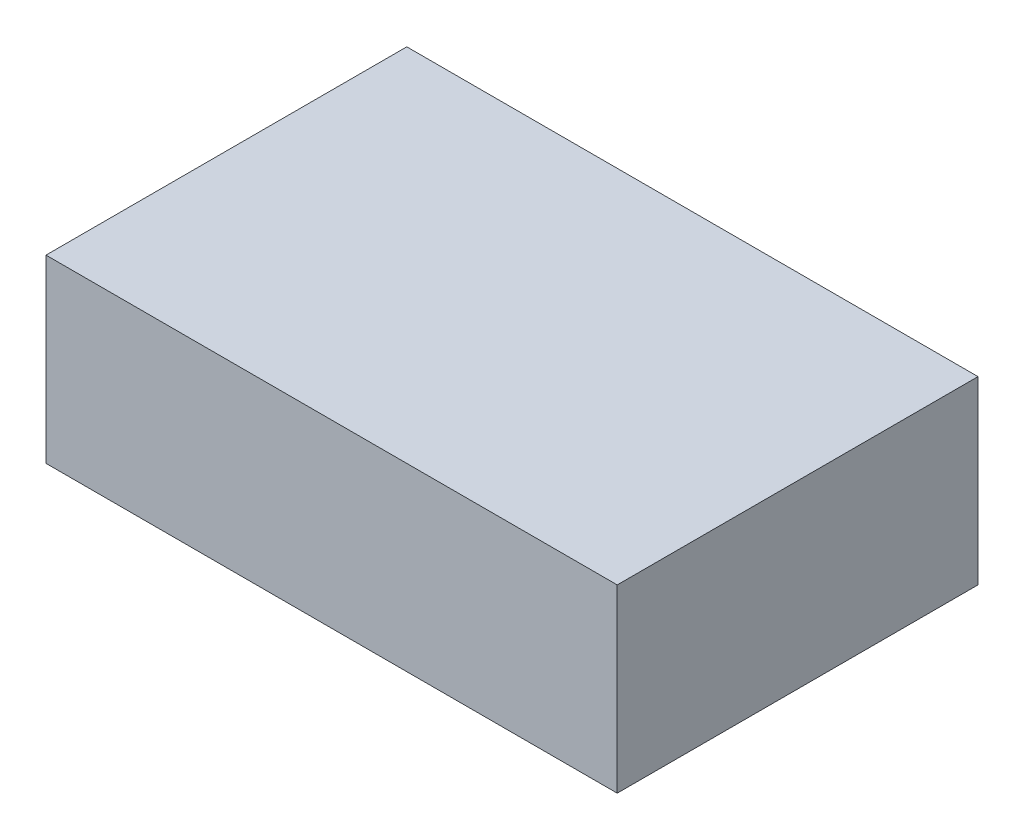
from build123d import *

# Parameters (mm, degrees)
SZKIC1_W                    = 380
SZKIC1_H                    = 240
DODANIE_WYCI_GNI_CIE1_DEPTH = 120


with BuildPart() as part:
    # Szkic1 → Dodanie-wyciągnięcie1 (new body)
    with BuildSketch(Plane(origin=(0, 0, 0), x_dir=(1, 0, 0), z_dir=(0, 1, 0))):
        Rectangle(SZKIC1_W, SZKIC1_H)
    extrude(amount=DODANIE_WYCI_GNI_CIE1_DEPTH)


solid = part.part
